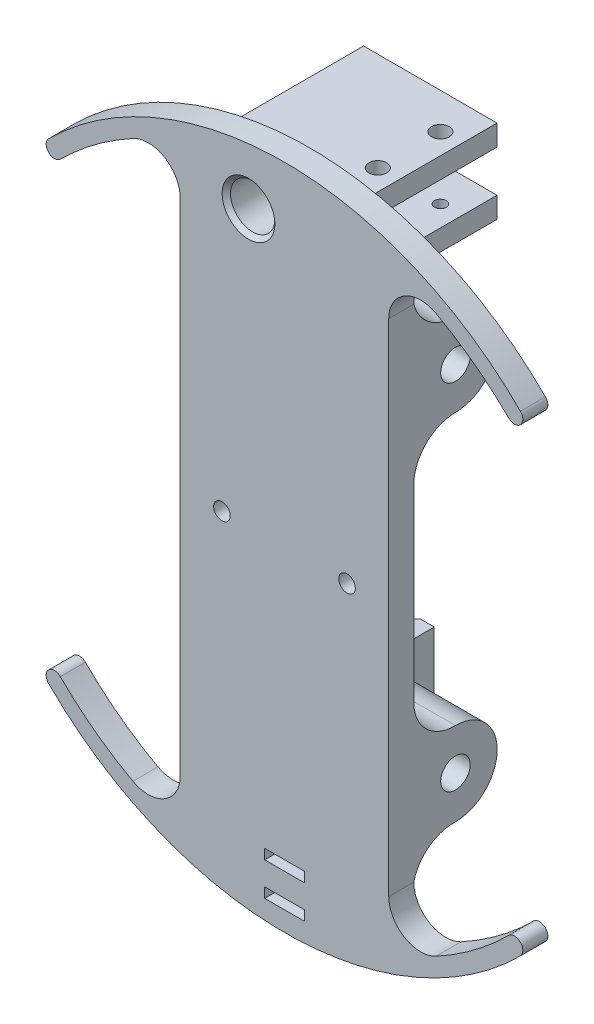
from build123d import *

# Parameters (mm, degrees)
MAIN_BODY_DEPTH                  = 3.81
CROSS_SCREW_BOSSES_DEPTH         = 31.75
F_8_CLEARANCE_HOLE1_D            = 4.4958
BALLOON_MONOFILAMENT_HOLE_D      = 2.5273
PARACHUTE_MONOFILAMENT_HOLE_D    = 2.5273
SKETCH21_W                       = 12.08
SKETCH21_H                       = 11.74
HOT_WIRE_CUTTER_HOLDER_DEPTH     = 9.67
CUT_EXTRUDE10_START              = -1.27
CUT_EXTRUDE10_DEPTH              = 63.383576094
CHAMFER8_SIZE                    = 0.381
SKETCH22_W                       = 6.029522694
SKETCH22_H                       = 1.524
SATELLITE_CABLE_MANAGEMENT_DEPTH = 66.050272386
SKETCH23_R                       = 3.175
BOSS_EXTRUDE7_DEPTH              = 20.066
SKETCH26_W                       = 6.35
SKETCH26_H                       = 6.35
CUT_EXTRUDE11_DEPTH              = 0.65024
CUT_EXTRUDE12_REACH              = 68.598
CUT_EXTRUDE12_END_RADIUS         = 3.3782
F_2_CLEARANCE_HOLE1_D            = 2.7051
F_2_CLEARANCE_HOLE1_DEPTH        = 3.175
TAP_DRILL_FOR_2_56_TAP1_D        = 1.778
TAP_DRILL_FOR_2_56_TAP1_DEPTH    = 3.175


with BuildPart() as part:
    # Sketch3 → Main body (new body)
    with BuildSketch(Plane.XY):
        with BuildLine():
            Line((-15.875, -38.1), (-15.875, 38.1))
            ThreePointArc((-15.875, 38.1), (-18.260491841, 42.291797068), (-23.082694008, 42.38179842))
            ThreePointArc((-23.082694008, 42.38179842), (-28.900226452, 38.649767283), (-34.12497326, 34.12497326))
            ThreePointArc((-34.12497326, 34.12497326), (-35.921024484, 34.12497326), (-35.921024484, 35.921024484))
            ThreePointArc((-35.921024484, 35.921024484), (0, 50.8), (35.921024484, 35.921024484))
            ThreePointArc((35.921024484, 35.921024484), (35.921024484, 34.12497326), (34.12497326, 34.12497326))
            ThreePointArc((34.12497326, 34.12497326), (28.900226452, 38.649767283), (23.082694008, 42.38179842))
            ThreePointArc((23.082694008, 42.38179842), (18.260491841, 42.291797068), (15.875, 38.1))
            Line((15.875, 38.1), (15.875, -38.1))
            ThreePointArc((15.875, -38.1), (18.260491841, -42.291797068), (23.082694008, -42.38179842))
            ThreePointArc((23.082694008, -42.38179842), (28.900226452, -38.649767283), (34.12497326, -34.12497326))
            ThreePointArc((34.12497326, -34.12497326), (35.921024484, -34.12497326), (35.921024484, -35.921024484))
            ThreePointArc((35.921024484, -35.921024484), (0, -50.8), (-35.921024484, -35.921024484))
            ThreePointArc((-35.921024484, -35.921024484), (-35.921024484, -34.12497326), (-34.12497326, -34.12497326))
            ThreePointArc((-34.12497326, -34.12497326), (-28.900226452, -38.649767283), (-23.082694008, -42.38179842))
            ThreePointArc((-23.082694008, -42.38179842), (-18.260491841, -42.291797068), (-15.875, -38.1))
        make_face()
    extrude(amount=MAIN_BODY_DEPTH)

    # Sketch5 → Cross screw bosses (add)
    with BuildSketch(Plane(origin=(15.875, 0, 0), x_dir=(0, 0, -1), z_dir=(1, 0, 0))):
        with BuildLine():
            Line((0, 38.1), (0, 26.99385))
            Line((0, 26.99385), (0, 14.29385))
            ThreePointArc((0, 14.29385), (1.86498297, 18.77886703), (6.35, 20.64385))
            ThreePointArc((6.35, 20.64385), (12.699998494, 26.998224058), (6.341251887, 33.343843974))
            ThreePointArc((6.341251887, 33.343843974), (2.338844583, 34.612930799), (0, 38.1))
        make_face()
        with BuildLine():
            ThreePointArc((6.261703048, -20.644463916), (1.864650947, -18.840779739), (0, -14.469233029))
            Line((0, -14.469233029), (0, -26.99385))
            Line((0, -26.99385), (0, -38.1))
            ThreePointArc((0, -38.1), (2.217611083, -34.670801888), (6.077775616, -33.338012189))
            ThreePointArc((6.077775616, -33.338012189), (6.213919542, -33.33945129), (6.35, -33.34385))
            ThreePointArc((6.35, -33.34385), (12.7, -26.99385), (6.35, -20.64385))
            ThreePointArc((6.35, -20.64385), (6.305852606, -20.644312569), (6.261703048, -20.644463916))
        make_face()
    extrude(amount=-CROSS_SCREW_BOSSES_DEPTH)

    # 8 Clearance Hole1 (through all)
    with Locations(Plane(origin=(15.875, 0, 0), x_dir=(0, 0, -1), z_dir=(1, 0, 0))):
        with Locations((6.35, 26.99385), (6.35, -26.893399733)):
            Hole(F_8_CLEARANCE_HOLE1_D / 2)

    # Balloon monofilament hole (through all)
    with Locations(Plane.XY.offset(3.81)):
        with Locations((-9.525, 0)):
            Hole(BALLOON_MONOFILAMENT_HOLE_D / 2)

    # Parachute monofilament hole (through all)
    with Locations(Plane.XY.offset(3.81)):
        with Locations((9.525, 0)):
            Hole(PARACHUTE_MONOFILAMENT_HOLE_D / 2)

    # Sketch21 → Hot wire cutter holder (add)
    with BuildSketch(Plane.XY.offset(-8.5979)):
        with Locations((-5.315, -27.056)):
            Rectangle(SKETCH21_W, SKETCH21_H)
    extrude(amount=-HOT_WIRE_CUTTER_HOLDER_DEPTH)

    # Sketch21_10 → Cut-Extrude10 (cut, through all)
    with BuildSketch(Plane.XY.offset(-8.5979).offset(CUT_EXTRUDE10_START)):
        with BuildLine():
            Line((-4.243, -30.386), (-2.315, -30.386))
            ThreePointArc((-2.315, -30.386), (-1.961446609, -30.239553391), (-1.815, -29.886))
            Line((-1.815, -29.886), (-1.815, -24.786))
            Line((-1.815, -24.786), (-1.765, -24.786))
            ThreePointArc((-1.765, -24.786), (-1.623578644, -24.727421356), (-1.565, -24.586))
            Line((-1.565, -24.586), (-1.565, -24.386))
            Line((-1.565, -24.386), (-1.815, -24.386))
            Line((-1.815, -24.386), (-1.815, -21.186))
            Line((-1.815, -21.186), (-8.815, -21.186))
            Line((-8.815, -21.186), (-8.815, -30.386))
            Line((-8.815, -30.386), (-7.418, -30.386))
            Line((-7.418, -30.386), (-7.418, -32.926))
            Line((-7.418, -32.926), (-4.243, -32.926))
            Line((-4.243, -32.926), (-4.243, -30.386))
        make_face()
    extrude(amount=-CUT_EXTRUDE10_DEPTH, mode=Mode.SUBTRACT)

    # Chamfer8
    chamfer8_edges = [part.edges().sort_by_distance(p)[0] for p in [
        (-8.1165, -30.386, -18.2679),
        (-8.815, -25.786, -18.2679),
        (-3.279, -30.386, -18.2679),
        (-1.961446609, -30.239553391, -18.2679),
        (-1.815, -27.336, -18.2679),
    ]]
    chamfer(chamfer8_edges, length=CHAMFER8_SIZE)

    # Sketch22 → satellite cable management (cut, through all)
    with BuildSketch(Plane(origin=(0, 0, 0), x_dir=(-1, 0, 0), z_dir=(0, 0, -1))):
        with Locations((0, -47.038383029)):
            Rectangle(SKETCH22_W, SKETCH22_H)
        with Locations((0, -41.958383029)):
            Rectangle(SKETCH22_W, SKETCH22_H)
    extrude(amount=-SATELLITE_CABLE_MANAGEMENT_DEPTH, mode=Mode.SUBTRACT)

    # Sketch23 → Boss-Extrude7 (add)
    with BuildSketch(Plane(origin=(0, 0, 0), x_dir=(-1, 0, 0), z_dir=(0, 0, -1))):
        Polygon((-8.490181608, 45.085), (1.161818392, 45.085), (1.161818392, 38.735), (-8.490181608, 38.735), (-8.490181608, 35.56), (11.829818392, 35.56), (11.829818392, 48.26), (-8.490181608, 48.26), align=None)
        with Locations((5.479818392, 41.91)):
            Circle(SKETCH23_R, mode=Mode.SUBTRACT)
    extrude(amount=BOSS_EXTRUDE7_DEPTH)

    # Sketch25 → 1_4 QR pin hole (revolve, cut)
    with BuildSketch(Plane(origin=(-5.479818392, 41.91, -20.066), x_dir=(0, 1, 0), z_dir=(1, 0, 0))):
        Polygon((0, 0), (0, 23.876), (4.0132, 23.876), (3.3782, 23.241), (3.3782, 0), align=None)
    revolve(axis=Axis((-5.479818392, 41.91, -26.416), (0, 0, 1)), mode=Mode.SUBTRACT)

    # Sketch26 → Cut-Extrude11 (cut)
    with BuildSketch(Plane(origin=(-1.161818392, 0, 0), x_dir=(0, 0, -1), z_dir=(1, 0, 0))):
        with Locations((7.366, 41.91)):
            Rectangle(SKETCH26_W, SKETCH26_H)
    extrude(amount=-CUT_EXTRUDE11_DEPTH, mode=Mode.SUBTRACT)

    # Cut-Extrude12: up to this cylinder (the profile starts outside it)
    cut_extrude12_end = Plane(origin=(-5.479818392, 41.91, -7.366), z_dir=(0, 0, -1)) * Cylinder(CUT_EXTRUDE12_END_RADIUS, 146.095802, mode=Mode.PRIVATE)
    # Sketch27 → Cut-Extrude12 (cut, up to the surface)
    with BuildSketch(Plane(origin=(-1.812058392, 0, 0), x_dir=(0, 0, -1), z_dir=(1, 0, 0)), mode=Mode.PRIVATE) as cut_extrude12_sk1:
        with BuildLine():
            ThreePointArc((9.271, 41.91), (9.125990509, 42.639011939), (8.713038418, 43.257038418))
            Line((8.713038418, 43.257038418), (6.018961582, 40.562961582))
            ThreePointArc((6.018961582, 40.562961582), (8.095011939, 40.150009491), (9.271, 41.91))
        make_face()
    cut_extrude12_tool1 = extrude(cut_extrude12_sk1.sketch, amount=-CUT_EXTRUDE12_REACH, mode=Mode.PRIVATE) - cut_extrude12_end
    add(cut_extrude12_tool1.solids().sort_by_distance((-1.812058, 41.338299, -7.937701))[0], mode=Mode.SUBTRACT)
    # Sketch27 → Cut-Extrude12 (cut, up to the surface)
    with BuildSketch(Plane(origin=(-1.812058392, 0, 0), x_dir=(0, 0, -1), z_dir=(1, 0, 0)), mode=Mode.PRIVATE) as cut_extrude12_sk2:
        with BuildLine():
            Line((6.018961582, 40.562961582), (8.713038418, 43.257038418))
            ThreePointArc((8.713038418, 43.257038418), (6.018961582, 43.257038418), (6.018961582, 40.562961582))
        make_face()
    cut_extrude12_tool2 = extrude(cut_extrude12_sk2.sketch, amount=-CUT_EXTRUDE12_REACH, mode=Mode.PRIVATE) - cut_extrude12_end
    add(cut_extrude12_tool2.solids().sort_by_distance((-1.812058, 42.481701, -6.794299))[0], mode=Mode.SUBTRACT)
    # Sketch27 → Cut-Extrude12 (cut, up to the surface)
    with BuildSketch(Plane(origin=(-1.812058392, 0, 0), x_dir=(0, 0, -1), z_dir=(1, 0, 0)), mode=Mode.PRIVATE) as cut_extrude12_sk3:
        with BuildLine():
            ThreePointArc((9.271, 41.91), (9.125990509, 42.639011939), (8.713038418, 43.257038418))
            Line((8.713038418, 43.257038418), (6.018961582, 40.562961582))
            ThreePointArc((6.018961582, 40.562961582), (8.095011939, 40.150009491), (9.271, 41.91))
        make_face()
    cut_extrude12_tool3 = extrude(cut_extrude12_sk3.sketch, amount=-CUT_EXTRUDE12_REACH, mode=Mode.PRIVATE) - cut_extrude12_end
    add(cut_extrude12_tool3.solids().sort_by_distance((-1.812058, 41.338299, -7.937701))[0], mode=Mode.SUBTRACT)
    # Sketch27 → Cut-Extrude12 (cut, up to the surface)
    with BuildSketch(Plane(origin=(-1.812058392, 0, 0), x_dir=(0, 0, -1), z_dir=(1, 0, 0)), mode=Mode.PRIVATE) as cut_extrude12_sk4:
        with BuildLine():
            Line((6.018961582, 40.562961582), (8.713038418, 43.257038418))
            ThreePointArc((8.713038418, 43.257038418), (6.018961582, 43.257038418), (6.018961582, 40.562961582))
        make_face()
    cut_extrude12_tool4 = extrude(cut_extrude12_sk4.sketch, amount=-CUT_EXTRUDE12_REACH, mode=Mode.PRIVATE) - cut_extrude12_end
    add(cut_extrude12_tool4.solids().sort_by_distance((-1.812058, 42.481701, -6.794299))[0], mode=Mode.SUBTRACT)

    # 2 Clearance Hole1
    with Locations(Plane(origin=(0, 48.26, 0), x_dir=(1, 0, 0), z_dir=(0, 1, 0))):
        with Locations((5.315181608, 5.08), (5.315181608, 14.605)):
            Hole(F_2_CLEARANCE_HOLE1_D / 2, depth=F_2_CLEARANCE_HOLE1_DEPTH)

    # Tap Drill for _2-56 Tap1
    with Locations(Plane(origin=(0, 38.735, 0), x_dir=(1, 0, 0), z_dir=(0, 1, 0))):
        with Locations((5.315181608, 14.605), (5.315181608, 5.08)):
            Hole(TAP_DRILL_FOR_2_56_TAP1_D / 2, depth=TAP_DRILL_FOR_2_56_TAP1_DEPTH)


solid = part.part
